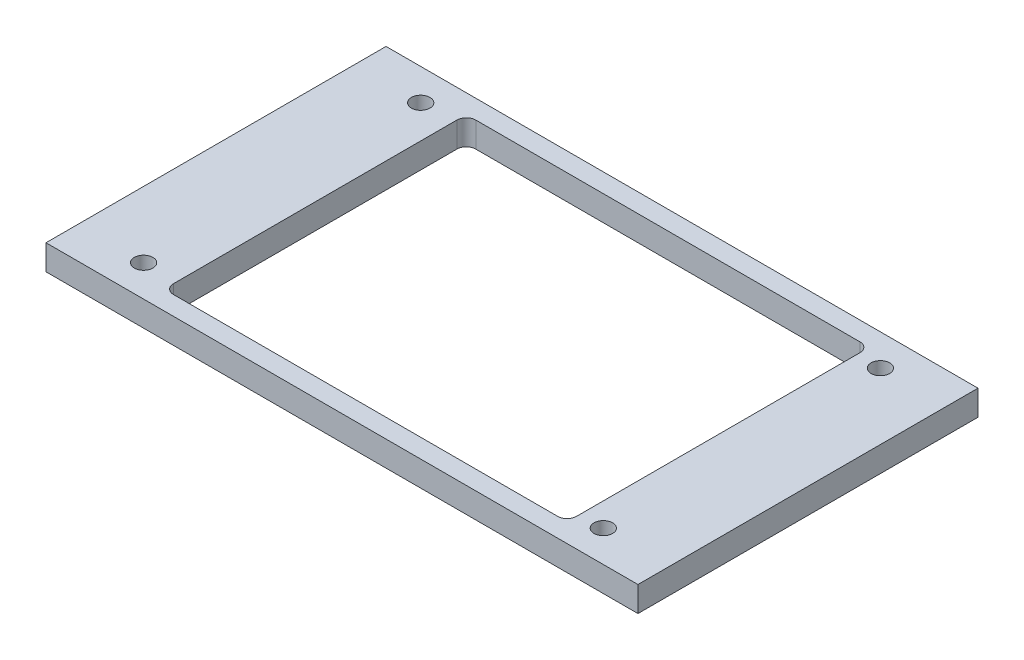
from build123d import *

# Parameters (mm, degrees)
SKETCH_1_W          = 188
SKETCH_1_H          = 108
EXTRUDE_1_DEPTH     = 8
SKETCH_2_R          = 2.95
SKETCH_2_W          = 128
SKETCH_2_H          = 96
CUT_EXTRUDE_1_DEPTH = 9
FILLET_1_R          = 3


with BuildPart() as part:
    # Эскиз1 → Бобышка-Вытянуть1 (new body)
    with BuildSketch(Plane(origin=(0, 0, 0), x_dir=(1, 0, 0), z_dir=(0, 1, 0))):
        Rectangle(SKETCH_1_W, SKETCH_1_H)
    extrude(amount=EXTRUDE_1_DEPTH)

    # Эскиз2 → Вырез-Вытянуть1 (cut, through all)
    with BuildSketch(Plane(origin=(0, 8, 0), x_dir=(1, 0, 0), z_dir=(0, 1, 0))):
        with Locations((-73, 44)):
            Circle(SKETCH_2_R)
        with Locations((73, 44)):
            Circle(SKETCH_2_R)
        with Locations((-73, -44)):
            Circle(SKETCH_2_R)
        with Locations((73, -44)):
            Circle(SKETCH_2_R)
        with Locations((1.5, 0)):
            Rectangle(SKETCH_2_W, SKETCH_2_H)
    extrude(amount=-CUT_EXTRUDE_1_DEPTH, mode=Mode.SUBTRACT)

    # Скругление1
    fillet_1_edges = [part.edges().sort_by_distance(p)[0] for p in [
        (65.5, 4, -48),
        (65.5, 4, 48),
        (-62.5, 4, 48),
        (-62.5, 4, -48),
    ]]
    fillet(fillet_1_edges, radius=FILLET_1_R)


solid = part.part
